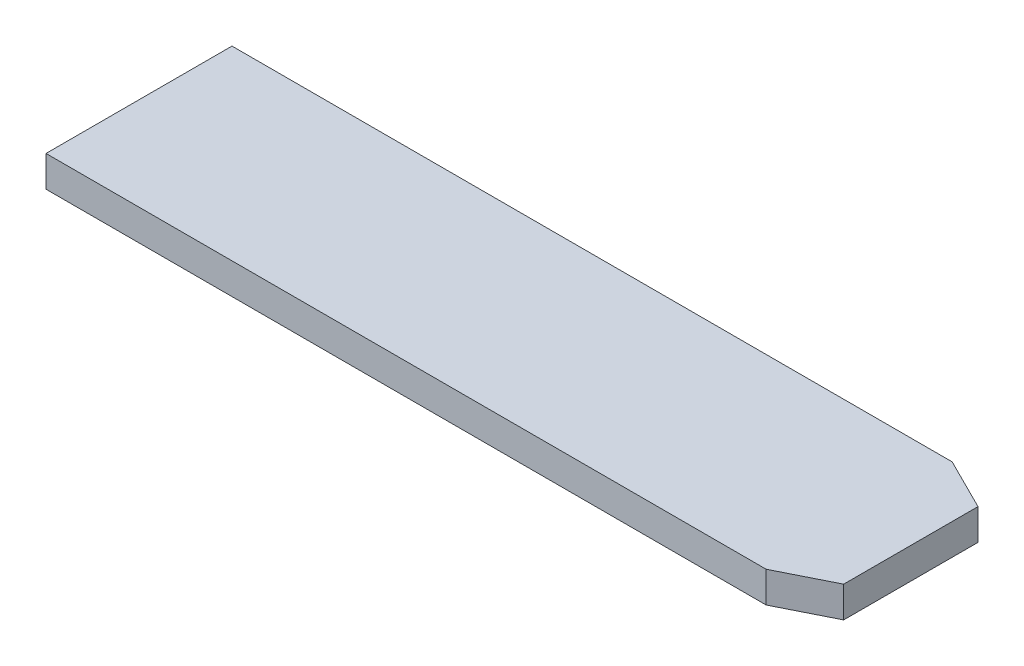
from build123d import *

# Parameters (mm, degrees)
SKETCH1_W           = 69.7
SKETCH1_H           = 18
BOSS_EXTRUDE1_DEPTH = 3
SKETCH3_W           = 13
SKETCH3_H           = 3


with BuildPart() as part:
    # Sketch1 → Boss-Extrude1 (new body)
    with BuildSketch(Plane(origin=(0, 0, 0), x_dir=(1, 0, 0), z_dir=(0, 1, 0))):
        Rectangle(SKETCH1_W, SKETCH1_H)
    extrude(amount=BOSS_EXTRUDE1_DEPTH)

    # Sketch3 → section 0 of loft1
    with BuildSketch(Plane(origin=(39.85, 0, 0), x_dir=(0, 0, -1), z_dir=(1, 0, 0)), mode=Mode.PRIVATE) as loft1_s0:
        with Locations((0, 1.5)):
            Rectangle(SKETCH3_W, SKETCH3_H)
    # loft up to a face of the part (loft1)
    loft([loft1_s0.sketch, part.faces().sort_by_distance((34.85, 1.5, 0))[0]])


solid = part.part
